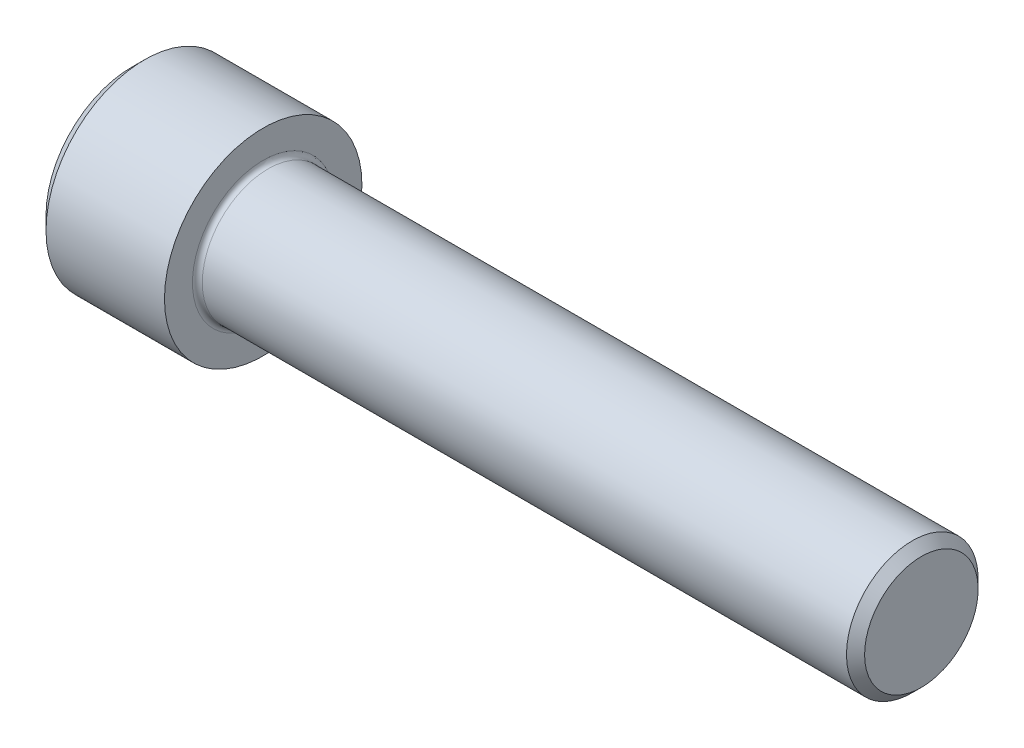
from build123d import *

# Parameters (mm, degrees)
FILLET1_R   = 0.6
HEX_2_DEPTH = 8


with BuildPart() as part:
    # BodySke → Base-Revolve (revolve)
    with BuildSketch(Plane.XY):
        Polygon((0, 0), (0, 10.4), (1.6, 12), (16, 12), (16, 8), (94.8985, 8), (96, 6.8985), (96, 0), align=None)
    revolve(axis=Axis((-31.75, 0, 0), (1, 0, 0)))

    # Fillet1
    fillet1_edges = [part.edges().sort_by_distance(p)[0] for p in [
        (16, -8, 0),
    ]]
    fillet(fillet1_edges, radius=FILLET1_R)

    # Sketch2 → Hex-PreBroach (revolve, cut)
    with BuildSketch(Plane.XY):
        Polygon((0, 7.071), (8, 7.071), (12.082443753, 0), (0, 0), align=None)
    revolve(axis=Axis((0, 0, 0), (1, 0, 0)), mode=Mode.SUBTRACT)

    # Sketch3 → Hex 2 (cut)
    with BuildSketch(Plane(origin=(0, 0, 0), x_dir=(0, 0.5, 0.866025404), z_dir=(-1, 0, 0))):
        Polygon((4.082443753, 7.071), (-4.082443753, 7.071), (-8.164887507, 0), (-4.082443753, -7.071), (4.082443753, -7.071), (8.164887507, 0), align=None)
    extrude(amount=-HEX_2_DEPTH, mode=Mode.SUBTRACT)


solid = part.part
